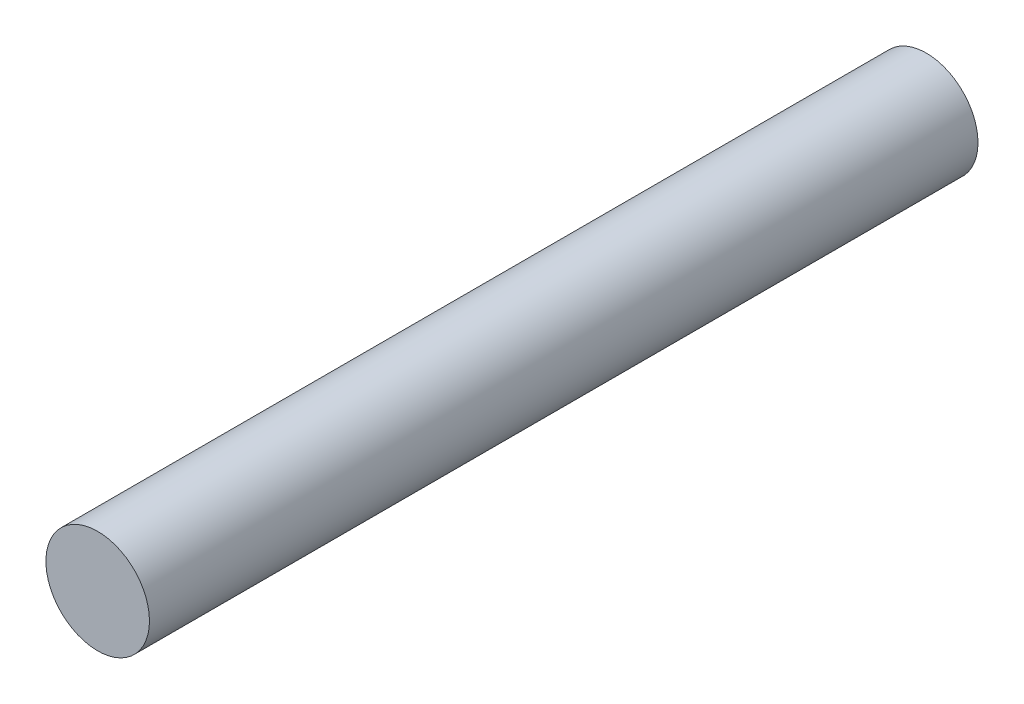
from build123d import *

# Parameters (mm, degrees)
SKETCH1_R           = 12.5
BOSS_EXTRUDE1_DEPTH = 200


with BuildPart() as part:
    # Sketch1 → Boss-Extrude1 (new body)
    with BuildSketch(Plane.XY):
        Circle(SKETCH1_R)
    extrude(amount=BOSS_EXTRUDE1_DEPTH)


solid = part.part
